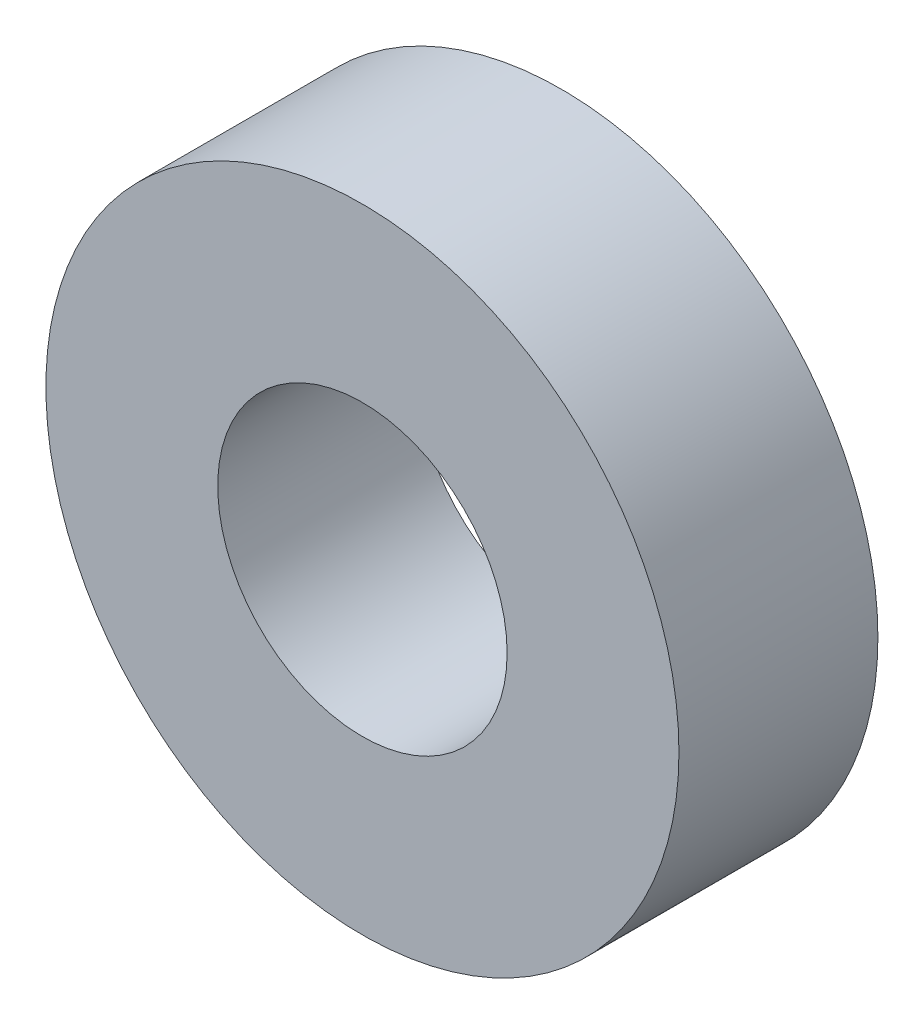
from build123d import *

# Parameters (mm, degrees)
SKETCH1_R           = 17.5
SKETCH1_R_2         = 8
BOSS_EXTRUDE1_DEPTH = 11


with BuildPart() as part:
    # Sketch1 → Boss-Extrude1 (new body)
    with BuildSketch(Plane.XY):
        Circle(SKETCH1_R)
        Circle(SKETCH1_R_2, mode=Mode.SUBTRACT)
    extrude(amount=BOSS_EXTRUDE1_DEPTH)


solid = part.part
